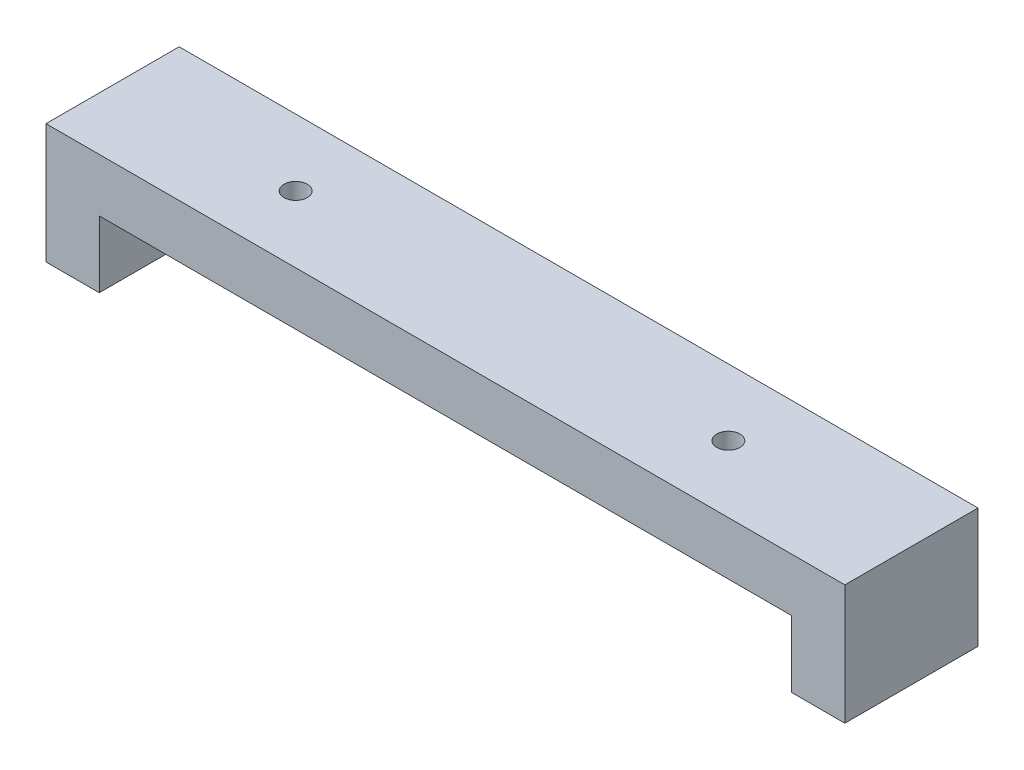
from build123d import *

# Parameters (mm, degrees)
SKETCH1_W           = 120
SKETCH1_H           = 20
BOSS_EXTRUDE1_DEPTH = 8
SKETCH2_W           = 8
SKETCH2_H           = 20
BOSS_EXTRUDE2_DEPTH = 10
SKETCH3_R           = 1.75
CUT_EXTRUDE1_DEPTH  = 10


with BuildPart() as part:
    # Sketch1 → Boss-Extrude1 (new body)
    with BuildSketch(Plane(origin=(0, 0, 0), x_dir=(1, 0, 0), z_dir=(0, 1, 0))):
        Rectangle(SKETCH1_W, SKETCH1_H)
    extrude(amount=BOSS_EXTRUDE1_DEPTH)

    # Sketch2 → Boss-Extrude2 (add)
    with BuildSketch(Plane.XZ):
        with Locations((56, 0)):
            Rectangle(SKETCH2_W, SKETCH2_H)
        with Locations((-56, 0)):
            Rectangle(SKETCH2_W, SKETCH2_H)
    extrude(amount=BOSS_EXTRUDE2_DEPTH)

    # Sketch3 → Cut-Extrude1 (cut)
    with BuildSketch(Plane.XZ):
        with Locations((32.5, 0)):
            Circle(SKETCH3_R)
        with Locations((-32.5, 0)):
            Circle(SKETCH3_R)
    extrude(amount=-CUT_EXTRUDE1_DEPTH, mode=Mode.SUBTRACT)


solid = part.part
